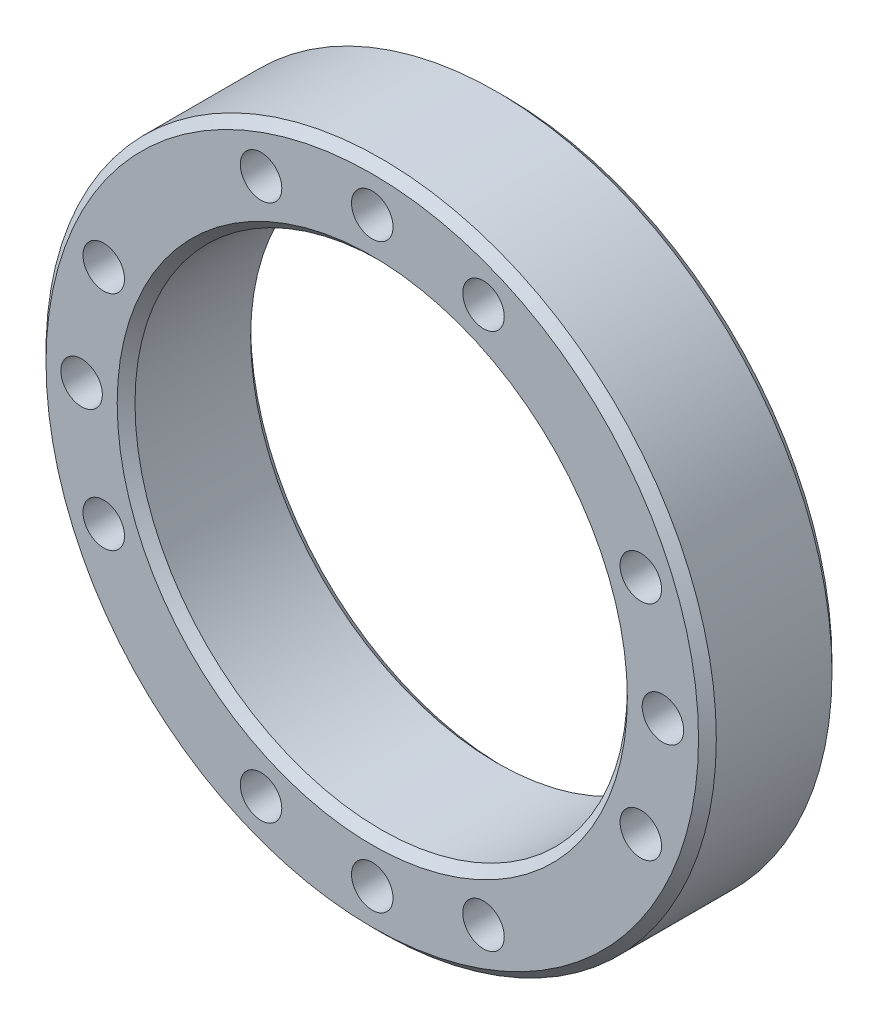
from build123d import *

# Parameters (mm, degrees)
SKETCH1_R              = 113
SKETCH1_R_2            = 83
BOSS_EXTRUDE1_DEPTH    = 22.5
CHAMFER1_SIZE          = 3
M16X2_0_TAPPED_HOLE1_D = 14
CIRPATTERN1_COUNT      = 4


with BuildPart() as part:
    # Sketch1 → Boss-Extrude1 (new body, symmetric)
    with BuildSketch(Plane.XY):
        Circle(SKETCH1_R)
        Circle(SKETCH1_R_2, mode=Mode.SUBTRACT)
    extrude(amount=BOSS_EXTRUDE1_DEPTH, both=True)

    # Chamfer1
    chamfer1_edges = [part.edges().sort_by_distance(p)[0] for p in [
        (-113, 0, -22.5),
        (-113, 0, 22.5),
        (-83, 0, -22.5),
        (-83, 0, 22.5),
    ]]
    chamfer(chamfer1_edges, length=CHAMFER1_SIZE)

    # M16x2.0 Tapped Hole1 (through all)
    with Locations(Plane.XY.offset(22.5)):
        with Locations((-37.502976372, 90.540194186), (37.502976372, 90.540194186), (0, 98)):
            m16x2_0_tapped_hole1 = Hole(M16X2_0_TAPPED_HOLE1_D / 2)

    # CirPattern1: M16x2.0 Tapped Hole1 ×4 about axis
    cirpattern1_axis = Axis((0, 0, 0), (0, 0, 1))
    for i in range(1, CIRPATTERN1_COUNT):
        add(m16x2_0_tapped_hole1.rotate(cirpattern1_axis, i * 360 / CIRPATTERN1_COUNT), mode=Mode.SUBTRACT)


solid = part.part
